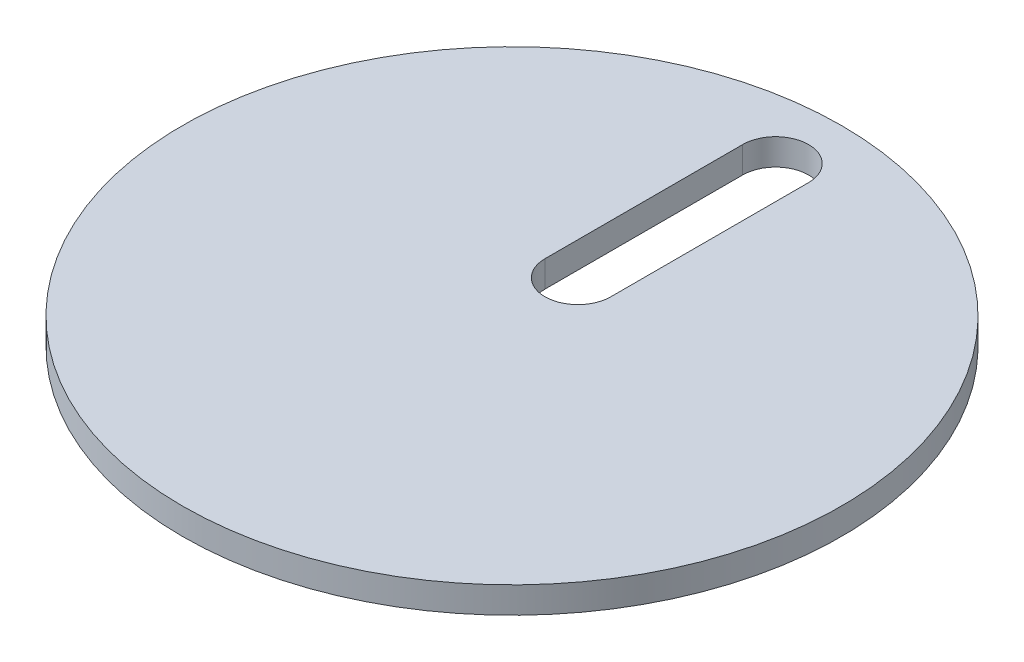
from build123d import *

# Parameters (mm, degrees)
SKETCH1_R           = 50
BOSS_EXTRUDE1_DEPTH = 4


with BuildPart() as part:
    # Sketch1 → Boss-Extrude1 (new body)
    with BuildSketch(Plane(origin=(0, 0, 0), x_dir=(1, 0, 0), z_dir=(0, 1, 0))):
        with Locations((0.107420937, 7.243062526)):
            Circle(SKETCH1_R)
        with BuildLine():
            Line((-4.892579063, 17.243062526), (-4.892579063, 47.243062526))
            ThreePointArc((-4.892579063, 47.243062526), (0.107420937, 52.243062526), (5.107420937, 47.243062526))
            Line((5.107420937, 47.243062526), (5.107420937, 17.243062526))
            ThreePointArc((5.107420937, 17.243062526), (0.107420937, 12.243062526), (-4.892579063, 17.243062526))
        make_face(mode=Mode.SUBTRACT)
    extrude(amount=BOSS_EXTRUDE1_DEPTH)


solid = part.part
